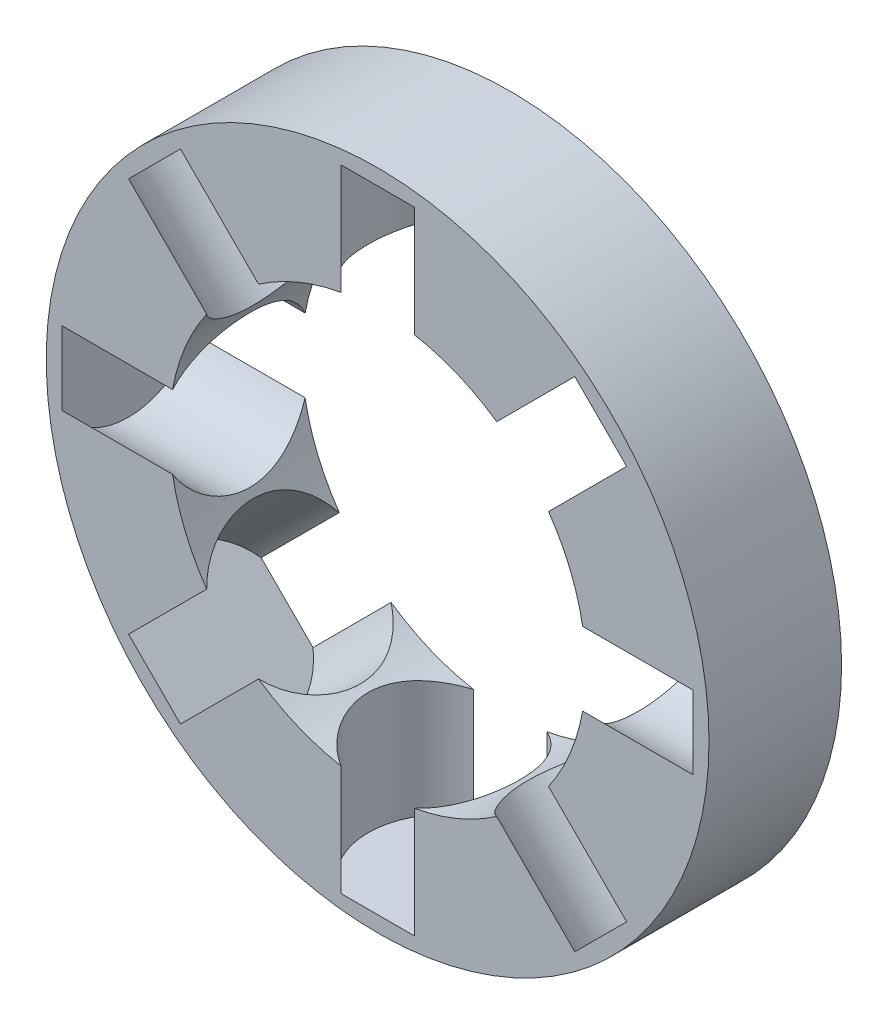
from build123d import *

# Parameters (mm, degrees)
SKETCH1_R           = 17.5
SKETCH1_R_2         = 11
BOSS_EXTRUDE1_DEPTH = 3.5
SKETCH4_R           = 4
CUT_EXTRUDE1_DEPTH  = 6.5
CIRPATTERN1_COUNT   = 8


with BuildPart() as part:
    # Sketch1 → Boss-Extrude1 (new, symmetric)
    with BuildSketch(Plane.XY):
        Circle(SKETCH1_R)
        Circle(SKETCH1_R_2, mode=Mode.SUBTRACT)
    extrude(amount=BOSS_EXTRUDE1_DEPTH, both=True)

    # Sketch4 → Cut-Extrude1 (cut)
    with BuildSketch(Plane(origin=(-10.162674858, 0, 0), x_dir=(0, 0, -1), z_dir=(1, 0, 0))):
        Circle(SKETCH4_R)
    cut_extrude1 = extrude(amount=-CUT_EXTRUDE1_DEPTH, mode=Mode.SUBTRACT)

    # CirPattern1: Cut-Extrude1 ×8 about axis
    cirpattern1_axis = Axis((0, 0, 3.5), (0, 0, -1))
    for i in range(1, CIRPATTERN1_COUNT):
        add(cut_extrude1.rotate(cirpattern1_axis, i * 360 / CIRPATTERN1_COUNT), mode=Mode.SUBTRACT)


solid = part.part
